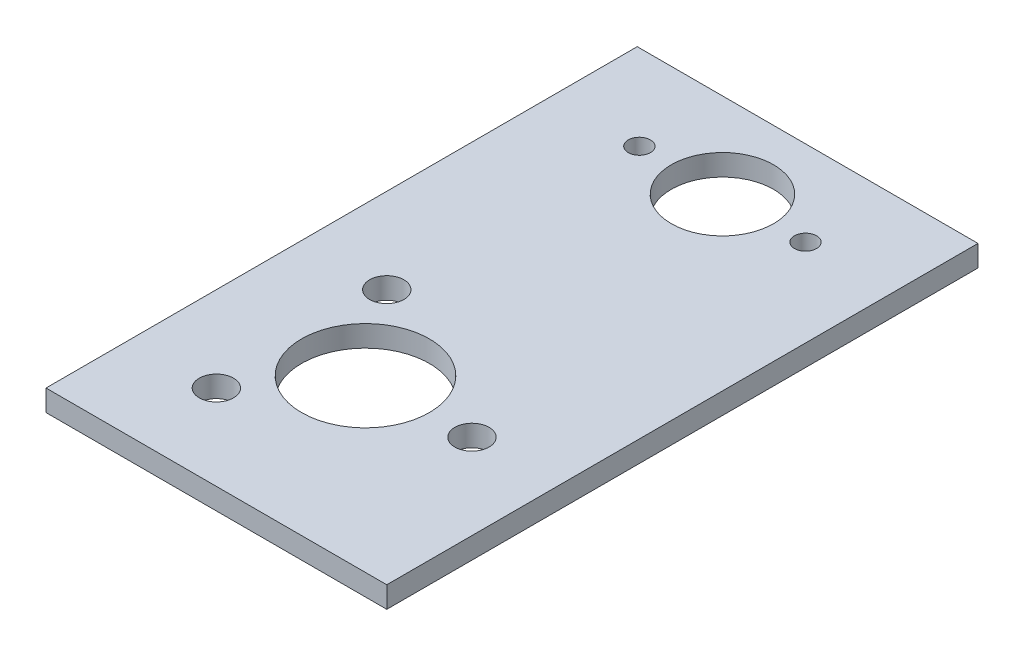
from build123d import *

# Parameters (mm, degrees)
SKETCH1_W           = 50.8
SKETCH1_H           = 88.138
BOSS_EXTRUDE1_DEPTH = 3.175
SKETCH2_R           = 2.5527
SKETCH2_R_2         = 9.525
CUT_EXTRUDE1_DEPTH  = 3.175
SKETCH4_R           = 1.651
SKETCH4_R_2         = 7.62
CUT_EXTRUDE2_DEPTH  = 3.175


with BuildPart() as part:
    # Sketch1 → Boss-Extrude1 (new body)
    with BuildSketch(Plane(origin=(0, 0, 0), x_dir=(1, 0, 0), z_dir=(0, 1, 0))):
        with Locations((25.4, 44.069)):
            Rectangle(SKETCH1_W, SKETCH1_H)
    extrude(amount=BOSS_EXTRUDE1_DEPTH)

    # Sketch2 → Cut-Extrude1 (cut)
    with BuildSketch(Plane(origin=(0, 3.175, 0), x_dir=(1, 0, 0), z_dir=(0, 1, 0))):
        with Locations((12.7, 12.7)):
            Circle(SKETCH2_R)
        with Locations((12.7, 38.1)):
            Circle(SKETCH2_R)
        with Locations((38.1, 25.4)):
            Circle(SKETCH2_R)
        with Locations((22.225, 25.4)):
            Circle(SKETCH2_R_2)
    extrude(amount=-CUT_EXTRUDE1_DEPTH, mode=Mode.SUBTRACT)

    # Sketch4 → Cut-Extrude2 (cut)
    with BuildSketch(Plane(origin=(0, 3.175, 0), x_dir=(1, 0, 0), z_dir=(0, 1, 0))):
        with Locations((13.0175, 75.438)):
            Circle(SKETCH4_R)
        with Locations((37.7825, 75.438)):
            Circle(SKETCH4_R)
        with Locations((25.4, 75.438)):
            Circle(SKETCH4_R_2)
    extrude(amount=-CUT_EXTRUDE2_DEPTH, mode=Mode.SUBTRACT)


solid = part.part
